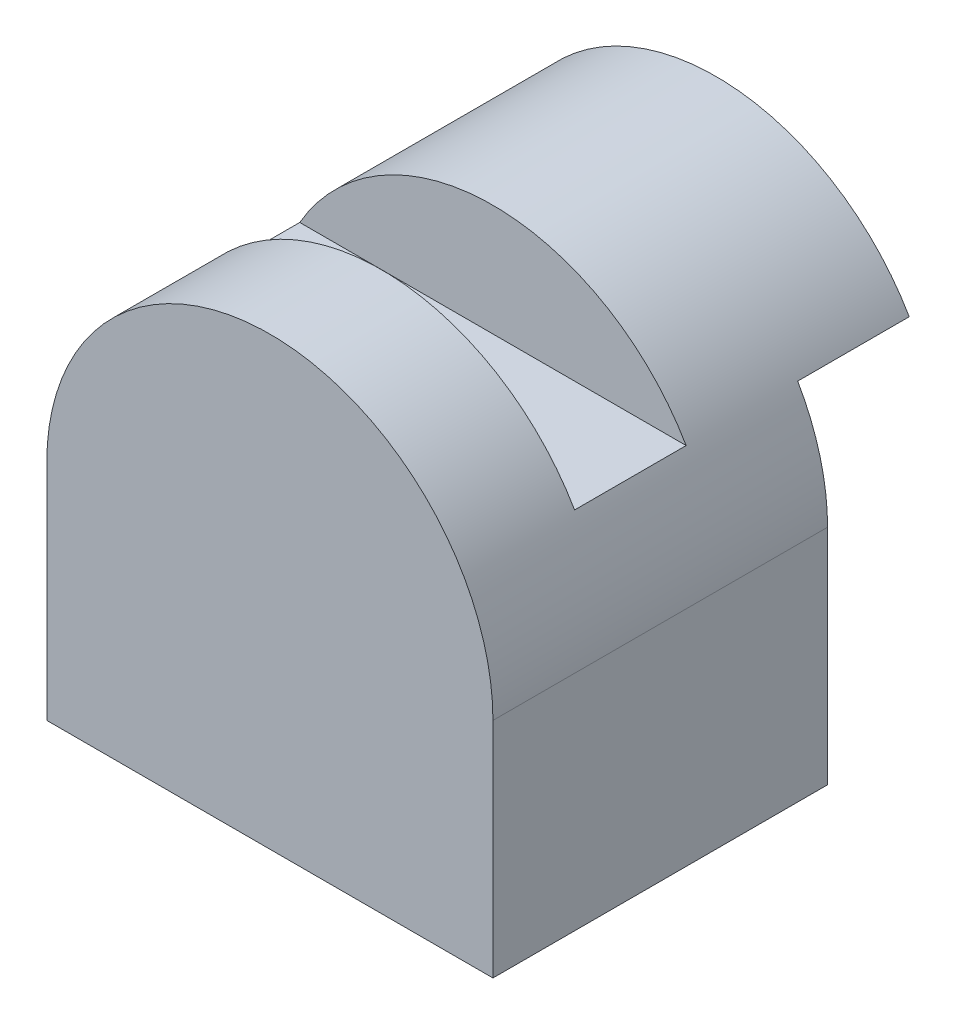
from build123d import *

# Parameters (mm, degrees)
BOSS_EXTRUDE1_DEPTH     = 40
SKETCH2_W               = 10
SKETCH2_H               = 30
SKETCH2_H_2             = 10
CUT_EXTRUDE1_DEPTH      = 40
CUT_EXTRUDE1_DEPTH_BACK = 40


with BuildPart() as part:
    # Sketch1 → Boss-Extrude1 (new body)
    with BuildSketch(Plane.XY):
        with BuildLine():
            Line((-20, 0), (-20, -20))
            Line((-20, -20), (20, -20))
            Line((20, -20), (20, 0))
            ThreePointArc((20, 0), (0, 20), (-20, 0))
        make_face()
    extrude(amount=BOSS_EXTRUDE1_DEPTH)

    # Sketch2 → Cut-Extrude1 (cut, two sides)
    with BuildSketch(Plane(origin=(0, 0, 0), x_dir=(0, 0, -1), z_dir=(1, 0, 0))) as cut_extrude1_sk:
        with Locations((-5, -5)):
            Rectangle(SKETCH2_W, SKETCH2_H)
        with Locations((-25, 15)):
            Rectangle(SKETCH2_W, SKETCH2_H_2)
    extrude(amount=CUT_EXTRUDE1_DEPTH, mode=Mode.SUBTRACT)
    extrude(cut_extrude1_sk.sketch, amount=-CUT_EXTRUDE1_DEPTH_BACK, mode=Mode.SUBTRACT)


solid = part.part
